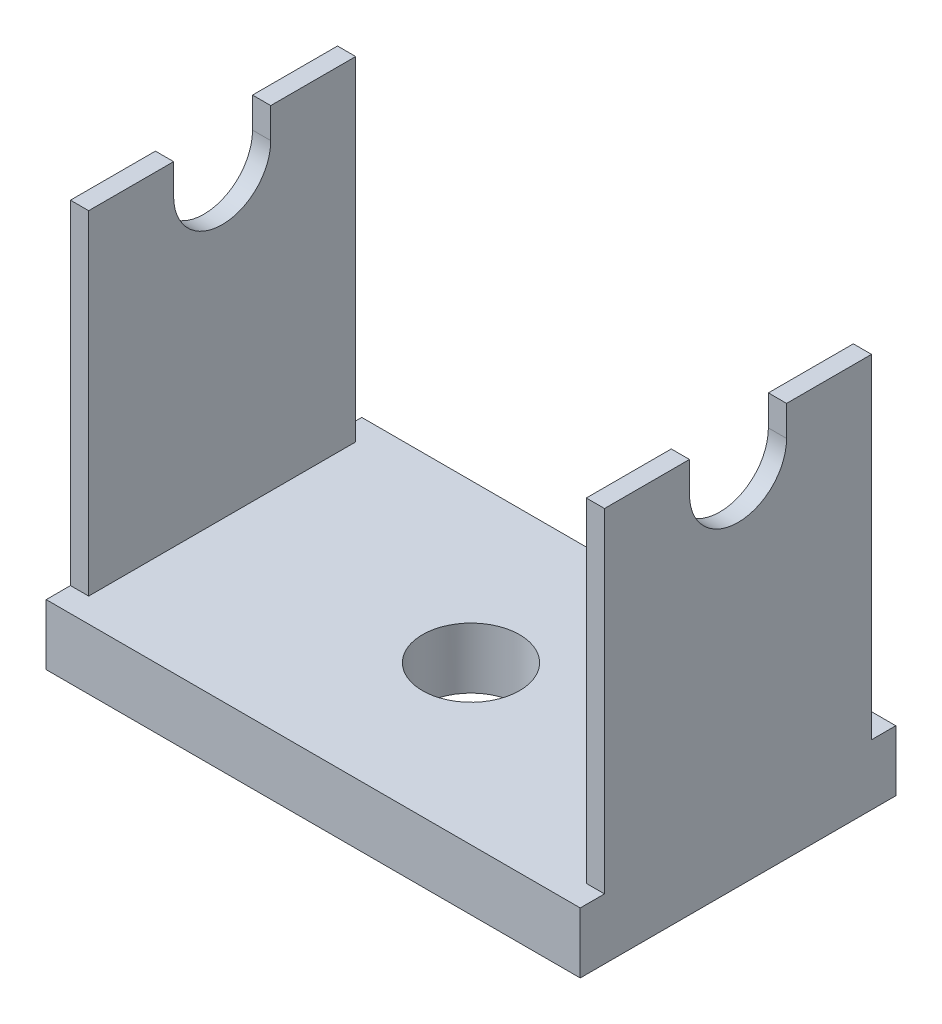
from build123d import *

# Parameters (mm, degrees)
BOSS_EXTRUDE1_DEPTH = 11
BOSS_EXTRUDE2_DEPTH = 19.5
SKETCH3_R           = 4
CUT_EXTRUDE1_DEPTH  = 2.5
CUT_EXTRUDE2_DEPTH  = 45
SKETCH5_W           = 44
SKETCH5_H           = 26
BOSS_EXTRUDE3_DEPTH = 5
SKETCH3_3_R         = 4
CUT_EXTRUDE3_DEPTH  = 5


with BuildPart() as part:
    # Sketch1 → Boss-Extrude1 (new body, symmetric)
    with BuildSketch(Plane.XY):
        Polygon((-22, 2.5), (-22, -30), (22, -30), (22, 2.5), (20.5, 2.5), (20.5, -28.5), (-20.5, -28.5), (-20.5, 2.5), align=None)
    extrude(amount=BOSS_EXTRUDE1_DEPTH, both=True)

    # Sketch2 → Boss-Extrude2 (add, symmetric)
    with BuildSketch(Plane(origin=(0, 0, 0), x_dir=(0, 0, -1), z_dir=(1, 0, 0))):
        Polygon((-11, -30), (-13, -30), (-13, -25), (-11.5, -25), (-11.5, -28.5), (-11, -28.5), align=None)
    boss_extrude2 = extrude(amount=BOSS_EXTRUDE2_DEPTH, both=True)

    # Mirror1: Boss-Extrude2 across plane
    add(boss_extrude2.mirror(Plane.XY))

    # Sketch3 → Cut-Extrude1 (cut, through all)
    with BuildSketch(Plane(origin=(0, -28.5, 0), x_dir=(-1, 0, 0), z_dir=(0, 1, 0))):
        Circle(SKETCH3_R)
    extrude(amount=-CUT_EXTRUDE1_DEPTH, mode=Mode.SUBTRACT)

    # Sketch4 → Cut-Extrude2 (cut, through all)
    with BuildSketch(Plane(origin=(22, 0, 0), x_dir=(0, 0, -1), z_dir=(1, 0, 0))):
        with BuildLine():
            Line((-4, 0), (-4, 2.5))
            Line((-4, 2.5), (4, 2.5))
            Line((4, 2.5), (4, 0))
            ThreePointArc((4, 0), (0, -4), (-4, 0))
        make_face()
    extrude(amount=-CUT_EXTRUDE2_DEPTH, mode=Mode.SUBTRACT)

    # Sketch5 → Boss-Extrude3 (add)
    with BuildSketch(Plane.XZ.offset(30)):
        Rectangle(SKETCH5_W, SKETCH5_H)
    extrude(amount=-BOSS_EXTRUDE3_DEPTH)

    # Sketch3_3 → Cut-Extrude3 (cut, symmetric)
    with BuildSketch(Plane(origin=(0, -28.5, 0), x_dir=(-1, 0, 0), z_dir=(0, 1, 0))):
        Circle(SKETCH3_3_R)
    extrude(amount=CUT_EXTRUDE3_DEPTH, both=True, mode=Mode.SUBTRACT)


solid = part.part
